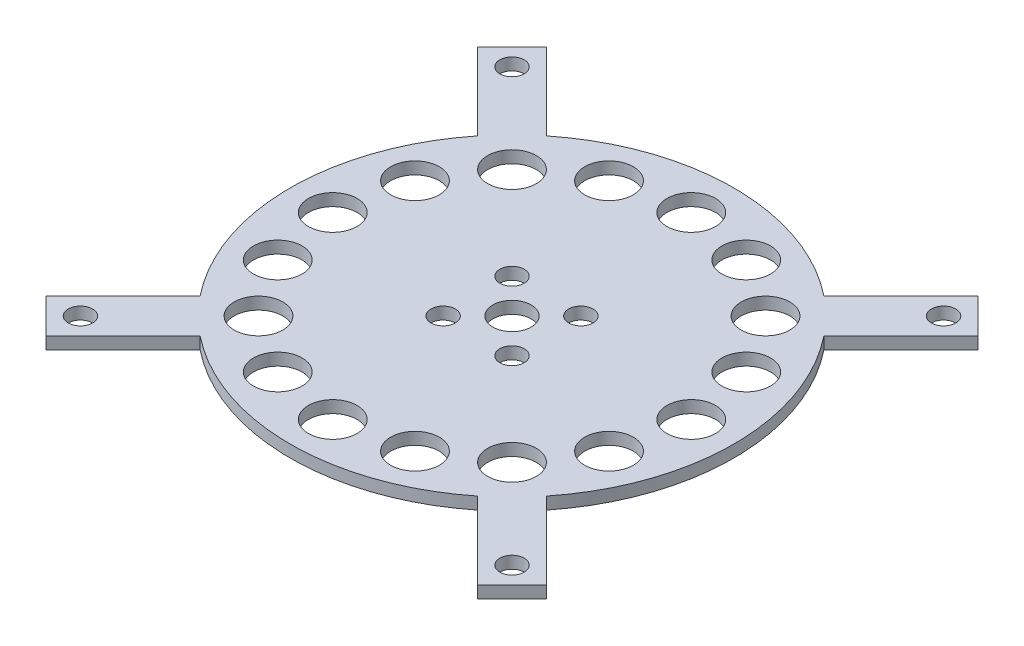
from build123d import *

# Parameters (mm, degrees)
SKETCH1_R                 = 5
BOSS_EXTRUDE1_DEPTH       = 3.175
SKETCH4_R                 = 6.35
BIG_INCO_PIN_HOLE_DEPTH   = 4.175
CIRPATTERN3_COUNT         = 16
SKETCH5_R                 = 3.175
SMALL_INCO_PIN_HOLE_DEPTH = 4.175
CIRPATTERN4_COUNT         = 4


with BuildPart() as part:
    # Sketch1 → Boss-Extrude1 (new body)
    with BuildSketch(Plane(origin=(0, 0, 0), x_dir=(1, 0, 0), z_dir=(0, 1, 0))):
        with BuildLine():
            Line((56.288245367, 65.268501488), (36.185821844, 45.166077965))
            ThreePointArc((36.185821844, 45.166077965), (0, 57.8739), (-36.185821844, 45.166077965))
            Line((-36.185821844, 45.166077965), (-56.288245367, 65.268501488))
            Line((-56.288245367, 65.268501488), (-65.268501488, 56.288245367))
            Line((-65.268501488, 56.288245367), (-45.166077965, 36.185821844))
            ThreePointArc((-45.166077965, 36.185821844), (-57.8739, 0), (-45.166077965, -36.185821844))
            Line((-45.166077965, -36.185821844), (-65.268501488, -56.288245367))
            Line((-65.268501488, -56.288245367), (-56.288245367, -65.268501488))
            Line((-56.288245367, -65.268501488), (-36.185821844, -45.166077965))
            ThreePointArc((-36.185821844, -45.166077965), (0, -57.8739), (36.185821844, -45.166077965))
            Line((36.185821844, -45.166077965), (56.288245367, -65.268501488))
            Line((56.288245367, -65.268501488), (65.268501488, -56.288245367))
            Line((65.268501488, -56.288245367), (45.166077965, -36.185821844))
            ThreePointArc((45.166077965, -36.185821844), (57.8739, 0), (45.166077965, 36.185821844))
            Line((45.166077965, 36.185821844), (65.268501488, 56.288245367))
            Line((65.268501488, 56.288245367), (56.288245367, 65.268501488))
        make_face()
        Circle(SKETCH1_R, mode=Mode.SUBTRACT)
    extrude(amount=BOSS_EXTRUDE1_DEPTH)

    # Sketch4 → Big Inco Pin Hole (cut, through all)
    with BuildSketch(Plane(origin=(0, 3.175, 0), x_dir=(1, 0, 0), z_dir=(0, 1, 0))):
        with Locations((46.7614, 0)):
            Circle(SKETCH4_R)
    big_inco_pin_hole = extrude(amount=-BIG_INCO_PIN_HOLE_DEPTH, mode=Mode.SUBTRACT)

    # CirPattern3: Big Inco Pin Hole ×16 about axis
    cirpattern3_axis = Axis((0, 0, 0), (0, 1, 0))
    for i in range(1, CIRPATTERN3_COUNT):
        add(big_inco_pin_hole.rotate(cirpattern3_axis, i * 360 / CIRPATTERN3_COUNT), mode=Mode.SUBTRACT)

    # Sketch5 → Small Inco Pin Hole (cut, through all)
    with BuildSketch(Plane(origin=(0, 3.175, 0), x_dir=(1, 0, 0), z_dir=(0, 1, 0))):
        with Locations((8.980256121, 8.980256121)):
            Circle(SKETCH5_R)
        with Locations((56.288245367, 56.288245367)):
            Circle(SKETCH5_R)
    small_inco_pin_hole = extrude(amount=-SMALL_INCO_PIN_HOLE_DEPTH, mode=Mode.SUBTRACT)

    # CirPattern4: Small Inco Pin Hole ×4 about axis
    cirpattern4_axis = Axis((0, 0, 0), (0, 1, 0))
    for i in range(1, CIRPATTERN4_COUNT):
        add(small_inco_pin_hole.rotate(cirpattern4_axis, i * 360 / CIRPATTERN4_COUNT), mode=Mode.SUBTRACT)


solid = part.part
